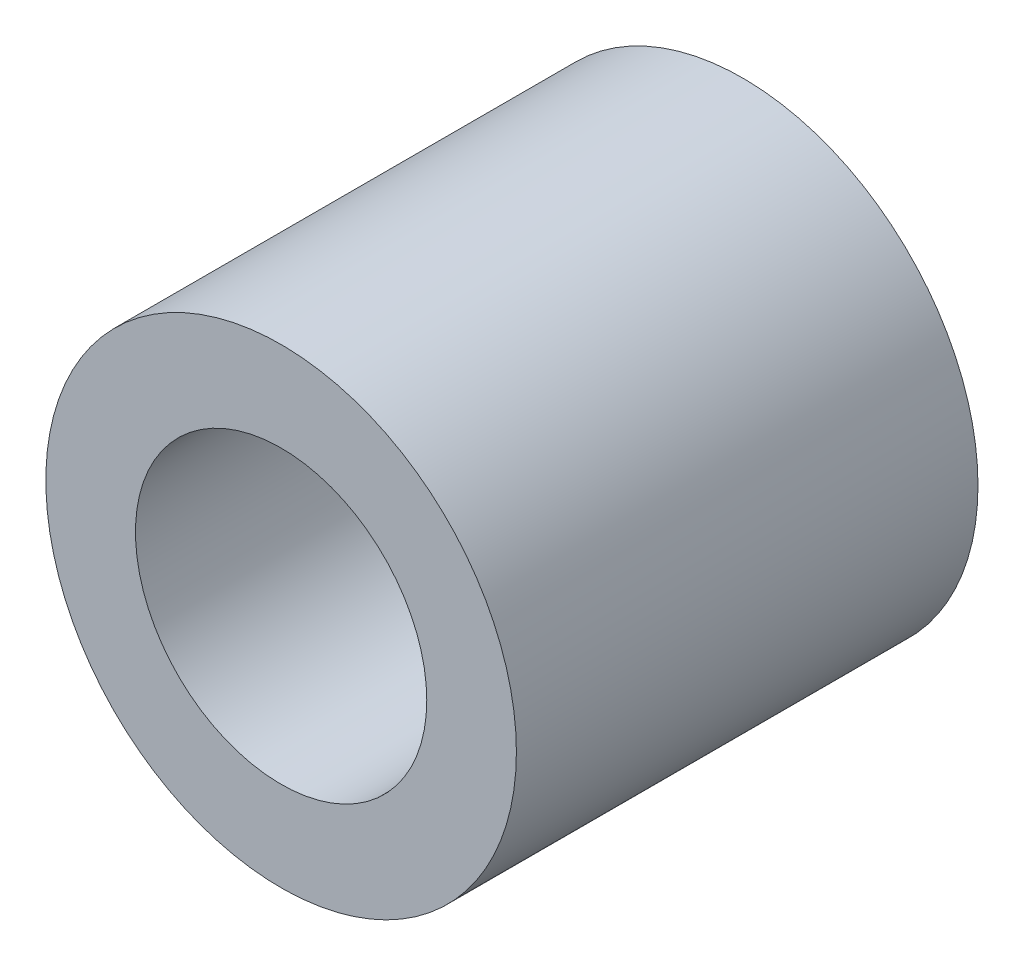
from build123d import *

# Parameters (mm, degrees)
SKETCH_1_R      = 5.25
SKETCH_1_R_2    = 3.25
EXTRUDE_1_DEPTH = 10.3


with BuildPart() as part:
    # 草图1 → 凸台-拉伸1 (new body)
    with BuildSketch(Plane.XY):
        Circle(SKETCH_1_R)
        Circle(SKETCH_1_R_2, mode=Mode.SUBTRACT)
    extrude(amount=EXTRUDE_1_DEPTH)


solid = part.part
